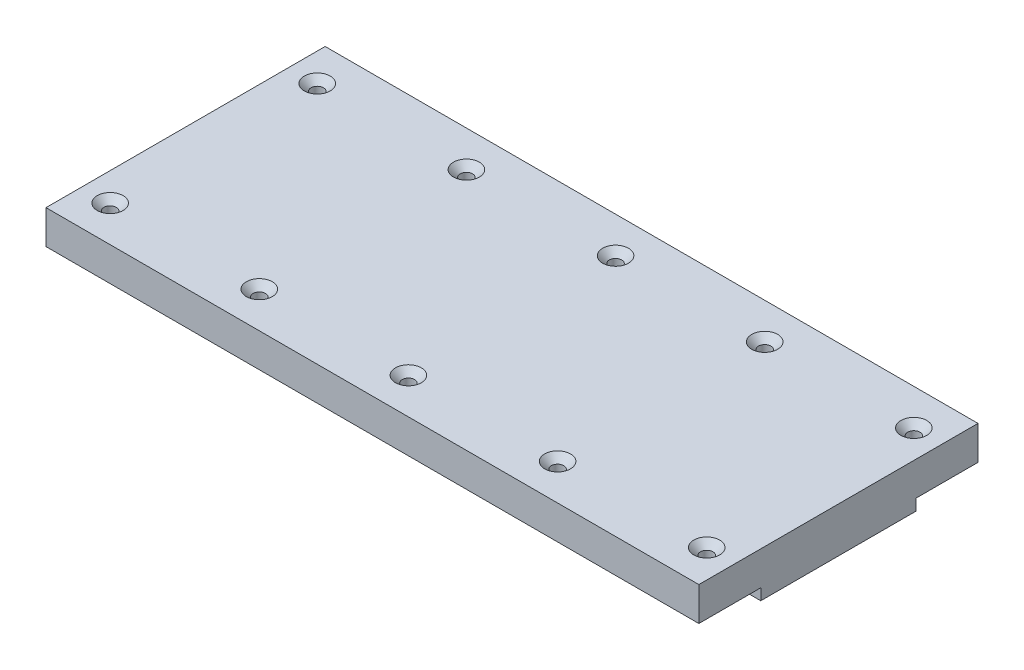
from build123d import *

# Parameters (mm, degrees)
SALIENTE_EXTRUIR1_DEPTH = 580
CORTAR_EXTRUIR1_REACH   = 42
CROQUIS3_R              = 5.5
CHAFL_N1_SIZE           = 6


with BuildPart() as part:
    # Croquis2 → Saliente-Extruir1 (new body)
    with BuildSketch(Plane(origin=(0, 0, 0), x_dir=(0, 0, -1), z_dir=(1, 0, 0))):
        Polygon((-69, -10), (69, -10), (69, 0), (124, 0), (124, 30), (-124, 30), (-124, 0), (-69, 0), align=None)
    extrude(amount=-SALIENTE_EXTRUIR1_DEPTH)

    # Croquis3 → Cortar-Extruir1 (cut, up to next)
    with BuildSketch(Plane(origin=(0, 30, 0), x_dir=(1, 0, 0), z_dir=(0, 1, 0)), mode=Mode.PRIVATE) as cortar_extruir1_sk1:
        with Locations((-555, 92)):
            Circle(CROQUIS3_R)
    cortar_extruir1_tool1 = extrude(cortar_extruir1_sk1.sketch, amount=-CORTAR_EXTRUIR1_REACH, mode=Mode.PRIVATE) & part.part
    add(cortar_extruir1_tool1.solids().sort_by_distance((-555, 30, -92))[0], mode=Mode.SUBTRACT)
    # Croquis3 → Cortar-Extruir1 (cut, up to next)
    with BuildSketch(Plane(origin=(0, 30, 0), x_dir=(1, 0, 0), z_dir=(0, 1, 0)), mode=Mode.PRIVATE) as cortar_extruir1_sk2:
        with Locations((-555, -92)):
            Circle(CROQUIS3_R)
    cortar_extruir1_tool2 = extrude(cortar_extruir1_sk2.sketch, amount=-CORTAR_EXTRUIR1_REACH, mode=Mode.PRIVATE) & part.part
    add(cortar_extruir1_tool2.solids().sort_by_distance((-555, 30, 92))[0], mode=Mode.SUBTRACT)
    # Croquis3 → Cortar-Extruir1 (cut, up to next)
    with BuildSketch(Plane(origin=(0, 30, 0), x_dir=(1, 0, 0), z_dir=(0, 1, 0)), mode=Mode.PRIVATE) as cortar_extruir1_sk3:
        with Locations((-422.5, 92)):
            Circle(CROQUIS3_R)
    cortar_extruir1_tool3 = extrude(cortar_extruir1_sk3.sketch, amount=-CORTAR_EXTRUIR1_REACH, mode=Mode.PRIVATE) & part.part
    add(cortar_extruir1_tool3.solids().sort_by_distance((-422.5, 30, -92))[0], mode=Mode.SUBTRACT)
    # Croquis3 → Cortar-Extruir1 (cut, up to next)
    with BuildSketch(Plane(origin=(0, 30, 0), x_dir=(1, 0, 0), z_dir=(0, 1, 0)), mode=Mode.PRIVATE) as cortar_extruir1_sk4:
        with Locations((-422.5, -92)):
            Circle(CROQUIS3_R)
    cortar_extruir1_tool4 = extrude(cortar_extruir1_sk4.sketch, amount=-CORTAR_EXTRUIR1_REACH, mode=Mode.PRIVATE) & part.part
    add(cortar_extruir1_tool4.solids().sort_by_distance((-422.5, 30, 92))[0], mode=Mode.SUBTRACT)
    # Croquis3 → Cortar-Extruir1 (cut, up to next)
    with BuildSketch(Plane(origin=(0, 30, 0), x_dir=(1, 0, 0), z_dir=(0, 1, 0)), mode=Mode.PRIVATE) as cortar_extruir1_sk5:
        with Locations((-290, 92)):
            Circle(CROQUIS3_R)
    cortar_extruir1_tool5 = extrude(cortar_extruir1_sk5.sketch, amount=-CORTAR_EXTRUIR1_REACH, mode=Mode.PRIVATE) & part.part
    add(cortar_extruir1_tool5.solids().sort_by_distance((-290, 30, -92))[0], mode=Mode.SUBTRACT)
    # Croquis3 → Cortar-Extruir1 (cut, up to next)
    with BuildSketch(Plane(origin=(0, 30, 0), x_dir=(1, 0, 0), z_dir=(0, 1, 0)), mode=Mode.PRIVATE) as cortar_extruir1_sk6:
        with Locations((-290, -92)):
            Circle(CROQUIS3_R)
    cortar_extruir1_tool6 = extrude(cortar_extruir1_sk6.sketch, amount=-CORTAR_EXTRUIR1_REACH, mode=Mode.PRIVATE) & part.part
    add(cortar_extruir1_tool6.solids().sort_by_distance((-290, 30, 92))[0], mode=Mode.SUBTRACT)
    # Croquis3 → Cortar-Extruir1 (cut, up to next)
    with BuildSketch(Plane(origin=(0, 30, 0), x_dir=(1, 0, 0), z_dir=(0, 1, 0)), mode=Mode.PRIVATE) as cortar_extruir1_sk7:
        with Locations((-157.5, 92)):
            Circle(CROQUIS3_R)
    cortar_extruir1_tool7 = extrude(cortar_extruir1_sk7.sketch, amount=-CORTAR_EXTRUIR1_REACH, mode=Mode.PRIVATE) & part.part
    add(cortar_extruir1_tool7.solids().sort_by_distance((-157.5, 30, -92))[0], mode=Mode.SUBTRACT)
    # Croquis3 → Cortar-Extruir1 (cut, up to next)
    with BuildSketch(Plane(origin=(0, 30, 0), x_dir=(1, 0, 0), z_dir=(0, 1, 0)), mode=Mode.PRIVATE) as cortar_extruir1_sk8:
        with Locations((-157.5, -92)):
            Circle(CROQUIS3_R)
    cortar_extruir1_tool8 = extrude(cortar_extruir1_sk8.sketch, amount=-CORTAR_EXTRUIR1_REACH, mode=Mode.PRIVATE) & part.part
    add(cortar_extruir1_tool8.solids().sort_by_distance((-157.5, 30, 92))[0], mode=Mode.SUBTRACT)
    # Croquis3 → Cortar-Extruir1 (cut, up to next)
    with BuildSketch(Plane(origin=(0, 30, 0), x_dir=(1, 0, 0), z_dir=(0, 1, 0)), mode=Mode.PRIVATE) as cortar_extruir1_sk9:
        with Locations((-25, 92)):
            Circle(CROQUIS3_R)
    cortar_extruir1_tool9 = extrude(cortar_extruir1_sk9.sketch, amount=-CORTAR_EXTRUIR1_REACH, mode=Mode.PRIVATE) & part.part
    add(cortar_extruir1_tool9.solids().sort_by_distance((-25, 30, -92))[0], mode=Mode.SUBTRACT)
    # Croquis3 → Cortar-Extruir1 (cut, up to next)
    with BuildSketch(Plane(origin=(0, 30, 0), x_dir=(1, 0, 0), z_dir=(0, 1, 0)), mode=Mode.PRIVATE) as cortar_extruir1_sk10:
        with Locations((-25, -92)):
            Circle(CROQUIS3_R)
    cortar_extruir1_tool10 = extrude(cortar_extruir1_sk10.sketch, amount=-CORTAR_EXTRUIR1_REACH, mode=Mode.PRIVATE) & part.part
    add(cortar_extruir1_tool10.solids().sort_by_distance((-25, 30, 92))[0], mode=Mode.SUBTRACT)

    # Chaflán1
    chafl_n1_edges = [part.edges().sort_by_distance(p)[0] for p in [
        (-295.5, 30, 92),
        (-163, 30, -92),
        (-163, 30, 92),
        (-30.5, 30, -92),
        (-560.5, 30, 92),
        (-428, 30, -92),
        (-428, 30, 92),
        (-295.5, 30, -92),
        (-30.5, 30, 92),
        (-560.5, 30, -92),
    ]]
    chamfer(chafl_n1_edges, length=CHAFL_N1_SIZE)


solid = part.part
